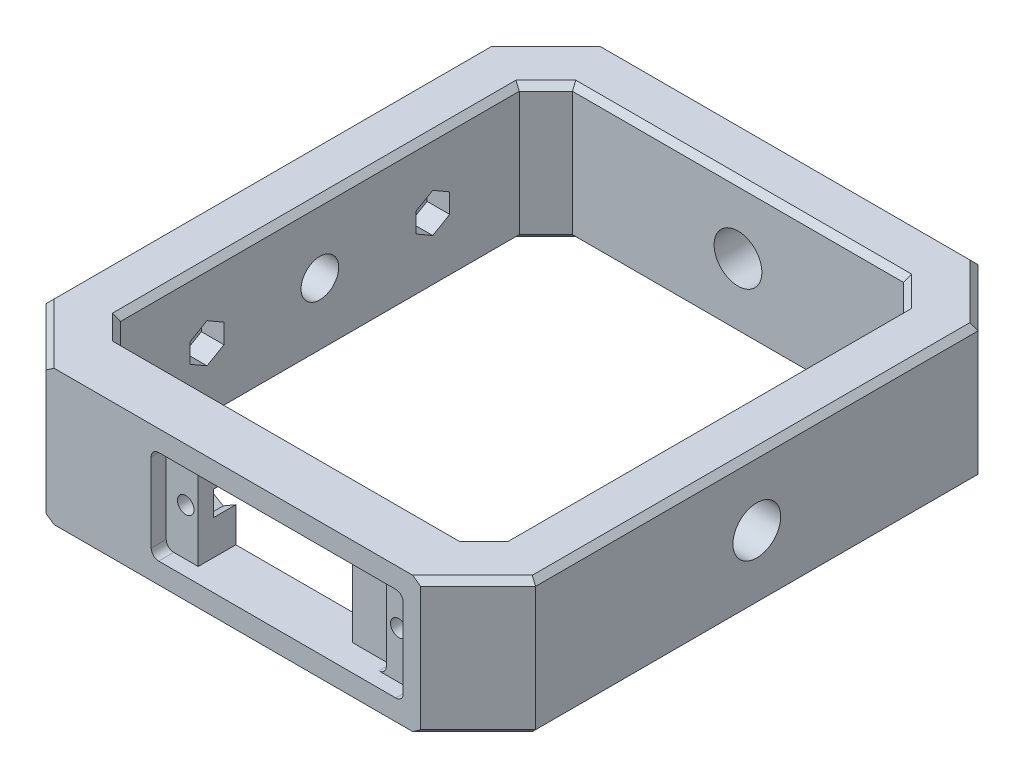
from build123d import *

# Parameters (mm, degrees)
BOSS_EXTRUDE1_DEPTH = 9
BEARING_HOLE_REACH  = 67.071
SKETCH11_R          = 3.175
CUT_EXTRUDE23_REACH = 67.071
SKETCH27_R          = 0.8
CUT_EXTRUDE25_DEPTH = 1.75
CUT_EXTRUDE26_REACH = 65.321
SKETCH28_R          = 2.5
CUT_EXTRUDE27_REACH = 76.071
SKETCH29_R          = 3.175
SKETCH35_W          = 33.5
SKETCH35_H          = 12.5
CUT_EXTRUDE29_DEPTH = 2
CUT_EXTRUDE30_REACH = 74.071
SKETCH36_W          = 25
SKETCH36_H          = 12.5
CUT_EXTRUDE31_REACH = 74.071
SKETCH37_R          = 1.1
FILLET1_R           = 1
SKETCH41_W          = 6
SKETCH41_H          = 12.5
BOSS_EXTRUDE4_DEPTH = 3.5
CUT_EXTRUDE32_DEPTH = 3
CUT_EXTRUDE33_DEPTH = 3
CHAMFER2_SIZE       = 0.75


with BuildPart() as part:
    # Sketch1 → Boss-Extrude1 (new body, symmetric)
    with BuildSketch(Plane(origin=(0, 0, 0), x_dir=(1, 0, 0), z_dir=(0, 1, 0))):
        Polygon((-32.535533906, 29.399494937), (-32.535533906, -29.399494937), (-24.899494937, -37.035533906), (24.899494937, -37.035533906), (32.535533906, -29.399494937), (32.535533906, 29.399494937), (24.899494937, 37.035533906), (-24.899494937, 37.035533906), align=None)
        Polygon((-25.535533906, 26.5), (-22, 30.035533906), (22, 30.035533906), (25.535533906, 26.5), (25.535533906, -26.5), (22, -30.035533906), (-22, -30.035533906), (-25.535533906, -26.5), align=None, mode=Mode.SUBTRACT)
    extrude(amount=BOSS_EXTRUDE1_DEPTH, both=True)

    # Sketch11 → Bearing Hole (cut, up to next)
    with BuildSketch(Plane(origin=(32.535533906, 0, 0), x_dir=(0, 0, -1), z_dir=(1, 0, 0)), mode=Mode.PRIVATE) as bearing_hole_sk1:
        Circle(SKETCH11_R)
    bearing_hole_tool1 = extrude(bearing_hole_sk1.sketch, amount=-BEARING_HOLE_REACH, mode=Mode.PRIVATE) & part.part
    add(bearing_hole_tool1.solids().sort_by_distance((32.535534, 0, 0))[0], mode=Mode.SUBTRACT)

    # Sketch27 → Cut-Extrude23 (cut, up to next)
    with BuildSketch(Plane.ZY.offset(32.535533906), mode=Mode.PRIVATE) as cut_extrude23_sk1:
        with Locations((-15, 0)):
            Circle(SKETCH27_R)
    cut_extrude23_tool1 = extrude(cut_extrude23_sk1.sketch, amount=-CUT_EXTRUDE23_REACH, mode=Mode.PRIVATE) & part.part
    add(cut_extrude23_tool1.solids().sort_by_distance((-32.535534, 0, -15))[0], mode=Mode.SUBTRACT)
    # Sketch27 → Cut-Extrude23 (cut, up to next)
    with BuildSketch(Plane.ZY.offset(32.535533906), mode=Mode.PRIVATE) as cut_extrude23_sk2:
        with Locations((15, 0)):
            Circle(SKETCH27_R)
    cut_extrude23_tool2 = extrude(cut_extrude23_sk2.sketch, amount=-CUT_EXTRUDE23_REACH, mode=Mode.PRIVATE) & part.part
    add(cut_extrude23_tool2.solids().sort_by_distance((-32.535534, 0, 15))[0], mode=Mode.SUBTRACT)

    # Sketch25 → Cut-Extrude25 (cut)
    with BuildSketch(Plane.ZY.offset(32.535533906)):
        with BuildLine():
            Line((-15.35, 3.48245603), (-0.5, 4.974937186))
            ThreePointArc((-0.5, 4.974937186), (0, 5), (0.5, 4.974937186))
            Line((0.5, 4.974937186), (15.35, 3.48245603))
            ThreePointArc((15.35, 3.48245603), (18.5, 0), (15.35, -3.48245603))
            Line((15.35, -3.48245603), (0.5, -4.974937186))
            ThreePointArc((0.5, -4.974937186), (0, -5), (-0.5, -4.974937186))
            Line((-0.5, -4.974937186), (-15.35, -3.48245603))
            ThreePointArc((-15.35, -3.48245603), (-18.5, 0), (-15.35, 3.48245603))
        make_face()
    extrude(amount=-CUT_EXTRUDE25_DEPTH, mode=Mode.SUBTRACT)

    # Sketch28 → Cut-Extrude26 (cut, up to next)
    with BuildSketch(Plane.ZY.offset(30.785533906), mode=Mode.PRIVATE) as cut_extrude26_sk1:
        Circle(SKETCH28_R)
    cut_extrude26_tool1 = extrude(cut_extrude26_sk1.sketch, amount=-CUT_EXTRUDE26_REACH, mode=Mode.PRIVATE) & part.part
    add(cut_extrude26_tool1.solids().sort_by_distance((-30.785534, 0, 0))[0], mode=Mode.SUBTRACT)

    # Sketch29 → Cut-Extrude27 (cut, up to next)
    with BuildSketch(Plane(origin=(0, 0, -37.035533906), x_dir=(-1, 0, 0), z_dir=(0, 0, -1)), mode=Mode.PRIVATE) as cut_extrude27_sk1:
        Circle(SKETCH29_R)
    cut_extrude27_tool1 = extrude(cut_extrude27_sk1.sketch, amount=-CUT_EXTRUDE27_REACH, mode=Mode.PRIVATE) & part.part
    add(cut_extrude27_tool1.solids().sort_by_distance((0, 0, -37.035534))[0], mode=Mode.SUBTRACT)

    # Sketch35 → Cut-Extrude29 (cut)
    with BuildSketch(Plane.XY.offset(37.035533906)):
        with Locations((5.83, 0)):
            Rectangle(SKETCH35_W, SKETCH35_H)
    extrude(amount=-CUT_EXTRUDE29_DEPTH, mode=Mode.SUBTRACT)

    # Sketch36 → Cut-Extrude30 (cut, up to next)
    with BuildSketch(Plane.XY.offset(35.035533906), mode=Mode.PRIVATE) as cut_extrude30_sk1:
        with Locations((5.83, 0)):
            Rectangle(SKETCH36_W, SKETCH36_H)
    cut_extrude30_tool1 = extrude(cut_extrude30_sk1.sketch, amount=-CUT_EXTRUDE30_REACH, mode=Mode.PRIVATE) & part.part
    add(cut_extrude30_tool1.solids().sort_by_distance((5.83, 0, 35.035534))[0], mode=Mode.SUBTRACT)

    # Sketch37 → Cut-Extrude31 (cut, up to next)
    with BuildSketch(Plane.XY.offset(35.035533906), mode=Mode.PRIVATE) as cut_extrude31_sk1:
        with Locations((19.9905, 0)):
            Circle(SKETCH37_R)
    cut_extrude31_tool1 = extrude(cut_extrude31_sk1.sketch, amount=-CUT_EXTRUDE31_REACH, mode=Mode.PRIVATE) & part.part
    add(cut_extrude31_tool1.solids().sort_by_distance((19.9905, 0, 35.035534))[0], mode=Mode.SUBTRACT)
    # Sketch37 → Cut-Extrude31 (cut, up to next)
    with BuildSketch(Plane.XY.offset(35.035533906), mode=Mode.PRIVATE) as cut_extrude31_sk2:
        with Locations((-8.3305, 0)):
            Circle(SKETCH37_R)
    cut_extrude31_tool2 = extrude(cut_extrude31_sk2.sketch, amount=-CUT_EXTRUDE31_REACH, mode=Mode.PRIVATE) & part.part
    add(cut_extrude31_tool2.solids().sort_by_distance((-8.3305, 0, 35.035534))[0], mode=Mode.SUBTRACT)

    # Fillet1
    fillet1_edges = [part.edges().sort_by_distance(p)[0] for p in [
        (22.58, 6.25, 36.035533906),
        (22.58, -6.25, 36.035533906),
        (-10.92, -6.25, 36.035533906),
        (-10.92, 6.25, 36.035533906),
        (18.33, 6.25, 32.535533906),
        (18.33, -6.25, 32.535533906),
        (-6.67, 6.25, 32.535533906),
    ]]
    fillet(fillet1_edges, radius=FILLET1_R)

    # Sketch41 → Boss-Extrude4 (add)
    with BuildSketch(Plane(origin=(0, 0, 30.035533906), x_dir=(-1, 0, 0), z_dir=(0, 0, -1))):
        with Locations((-15.33, 0)):
            Rectangle(SKETCH41_W, SKETCH41_H)
    extrude(amount=-BOSS_EXTRUDE4_DEPTH)

    # Sketch42 → Cut-Extrude32 (cut)
    with BuildSketch(Plane(origin=(-25.535533906, 0, 0), x_dir=(0, 0, -1), z_dir=(1, 0, 0))):
        Polygon((-12.75, -1.299038106), (-12.75, 1.299038106), (-15, 2.598076211), (-17.25, 1.299038106), (-17.25, -1.299038106), (-15, -2.598076211), align=None)
        Polygon((17.25, 1.299038106), (15, 2.598076211), (12.75, 1.299038106), (12.75, -1.299038106), (15, -2.598076211), (17.25, -1.299038106), align=None)
    extrude(amount=-CUT_EXTRUDE32_DEPTH, mode=Mode.SUBTRACT)

    # Sketch43 → Cut-Extrude33 (cut)
    with BuildSketch(Plane(origin=(0, 0, 30.035533906), x_dir=(-1, 0, 0), z_dir=(0, 0, -1))):
        Polygon((-17.7405, -1.299038106), (-17.7405, 1.299038106), (-19.9905, 2.598076211), (-22.2405, 1.299038106), (-22.2405, -1.299038106), (-19.9905, -2.598076211), align=None)
        Polygon((6.0805, -1.299038106), (8.3305, -2.598076211), (10.5805, -1.299038106), (10.5805, 1.299038106), (8.3305, 2.598076211), (6.0805, 1.299038106), align=None)
    extrude(amount=-CUT_EXTRUDE33_DEPTH, mode=Mode.SUBTRACT)

    # Chamfer2
    chamfer2_edges = [part.edges().sort_by_distance(p)[0] for p in [
        (-28.717514421, 9, 33.217514421),
        (-32.535533906, -9, 0),
        (-28.717514421, -9, -33.217514421),
        (28.717514421, 9, 33.217514421),
        (32.535533906, 9, 0),
        (28.717514421, 9, -33.217514421),
        (0, 9, -37.035533906),
        (-25.535533906, -9, 0),
        (-23.767766953, -9, 28.267766953),
        (23.767766953, -9, 28.267766953),
        (25.535533906, -9, 0),
        (23.767766953, -9, -28.267766953),
        (0, -9, -30.035533906),
        (-23.767766953, -9, -28.267766953),
        (-25.535533906, 9, 0),
        (-23.767766953, 9, 28.267766953),
        (23.767766953, 9, 28.267766953),
        (25.535533906, 9, 0),
        (23.767766953, 9, -28.267766953),
        (0, 9, -30.035533906),
        (-23.767766953, 9, -28.267766953),
        (-28.717514421, 9, -33.217514421),
        (-32.535533906, 9, 0),
        (0, -9, -37.035533906),
        (28.717514421, -9, -33.217514421),
        (32.535533906, -9, 0),
        (28.717514421, -9, 33.217514421),
        (-28.717514421, -9, 33.217514421),
    ]]
    chamfer(chamfer2_edges, length=CHAMFER2_SIZE)


solid = part.part
